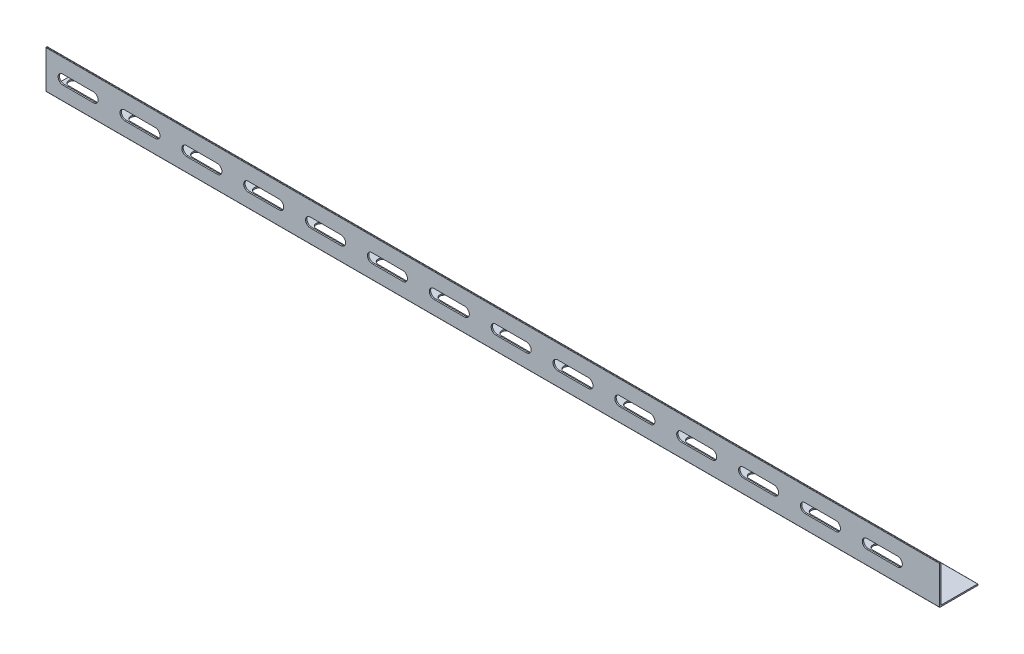
from build123d import *

# Parameters (mm, degrees)
EXTRUDE_1_DEPTH     = 650
CUT_EXTRUDE_1_REACH = 30
CUT_EXTRUDE_2_REACH = 3


with BuildPart() as part:
    # 草图1 → 凸台-拉伸1 (new body)
    with BuildSketch(Plane(origin=(0, 0, 0), x_dir=(0, 0, -1), z_dir=(1, 0, 0))):
        with BuildLine():
            Line((0, 0), (-5.481376518, 0))
            ThreePointArc((-5.481376518, 0), (-5.693508553, 0.087867966), (-5.781376518, 0.3))
            Line((-5.781376518, 0.3), (-5.781376518, 27.7))
            ThreePointArc((-5.781376518, 27.7), (-5.693508553, 27.912132034), (-5.481376518, 28))
            Line((-5.481376518, 28), (-5.081376518, 28))
            ThreePointArc((-5.081376518, 28), (-4.869244484, 27.912132034), (-4.781376518, 27.7))
            Line((-4.781376518, 27.7), (-4.781376518, 1.3))
            ThreePointArc((-4.781376518, 1.3), (-4.693508553, 1.087867966), (-4.481376518, 1))
            Line((-4.481376518, 1), (21.918623482, 1))
            ThreePointArc((21.918623482, 1), (22.130755516, 0.912132034), (22.218623482, 0.7))
            Line((22.218623482, 0.7), (22.218623482, 0.3))
            ThreePointArc((22.218623482, 0.3), (22.130755516, 0.087867966), (21.918623482, 0))
            Line((21.918623482, 0), (0, 0))
        make_face()
    extrude(amount=EXTRUDE_1_DEPTH)

    # 草图2 → 切除-拉伸1 (cut, up to next)
    with BuildSketch(Plane.XY.offset(5.781376518), mode=Mode.PRIVATE) as cut_extrude_1_sk1:
        with BuildLine():
            Line((12.252327797, 17.149656468), (34.50863052, 17.149656468))
            ThreePointArc((34.50863052, 17.149656468), (37.943978067, 13.714308921), (34.50863052, 10.278961375))
            Line((34.50863052, 10.278961375), (12.252327797, 10.278961375))
            ThreePointArc((12.252327797, 10.278961375), (8.816980251, 13.714308921), (12.252327797, 17.149656468))
        make_face()
    cut_extrude_1_tool1 = extrude(cut_extrude_1_sk1.sketch, amount=-CUT_EXTRUDE_1_REACH, mode=Mode.PRIVATE) & part.part
    add(cut_extrude_1_tool1.solids().sort_by_distance((23.380479, 13.714309, 5.781377))[0], mode=Mode.SUBTRACT)
    # 草图2 → 切除-拉伸1 (cut, up to next)
    with BuildSketch(Plane.XY.offset(5.781376518), mode=Mode.PRIVATE) as cut_extrude_1_sk2:
        with BuildLine():
            Line((57.252327797, 17.149656468), (79.50863052, 17.149656468))
            ThreePointArc((79.50863052, 17.149656468), (82.943978067, 13.714308921), (79.50863052, 10.278961375))
            Line((79.50863052, 10.278961375), (57.252327797, 10.278961375))
            ThreePointArc((57.252327797, 10.278961375), (53.816980251, 13.714308921), (57.252327797, 17.149656468))
        make_face()
    cut_extrude_1_tool2 = extrude(cut_extrude_1_sk2.sketch, amount=-CUT_EXTRUDE_1_REACH, mode=Mode.PRIVATE) & part.part
    add(cut_extrude_1_tool2.solids().sort_by_distance((68.380479, 13.714309, 5.781377))[0], mode=Mode.SUBTRACT)
    # 草图2 → 切除-拉伸1 (cut, up to next)
    with BuildSketch(Plane.XY.offset(5.781376518), mode=Mode.PRIVATE) as cut_extrude_1_sk3:
        with BuildLine():
            Line((102.252327797, 17.149656468), (124.50863052, 17.149656468))
            ThreePointArc((124.50863052, 17.149656468), (127.943978067, 13.714308921), (124.50863052, 10.278961375))
            Line((124.50863052, 10.278961375), (102.252327797, 10.278961375))
            ThreePointArc((102.252327797, 10.278961375), (98.816980251, 13.714308921), (102.252327797, 17.149656468))
        make_face()
    cut_extrude_1_tool3 = extrude(cut_extrude_1_sk3.sketch, amount=-CUT_EXTRUDE_1_REACH, mode=Mode.PRIVATE) & part.part
    add(cut_extrude_1_tool3.solids().sort_by_distance((113.380479, 13.714309, 5.781377))[0], mode=Mode.SUBTRACT)
    # 草图2 → 切除-拉伸1 (cut, up to next)
    with BuildSketch(Plane.XY.offset(5.781376518), mode=Mode.PRIVATE) as cut_extrude_1_sk4:
        with BuildLine():
            Line((147.252327797, 17.149656468), (169.50863052, 17.149656468))
            ThreePointArc((169.50863052, 17.149656468), (172.943978067, 13.714308921), (169.50863052, 10.278961375))
            Line((169.50863052, 10.278961375), (147.252327797, 10.278961375))
            ThreePointArc((147.252327797, 10.278961375), (143.816980251, 13.714308921), (147.252327797, 17.149656468))
        make_face()
    cut_extrude_1_tool4 = extrude(cut_extrude_1_sk4.sketch, amount=-CUT_EXTRUDE_1_REACH, mode=Mode.PRIVATE) & part.part
    add(cut_extrude_1_tool4.solids().sort_by_distance((158.380479, 13.714309, 5.781377))[0], mode=Mode.SUBTRACT)
    # 草图2 → 切除-拉伸1 (cut, up to next)
    with BuildSketch(Plane.XY.offset(5.781376518), mode=Mode.PRIVATE) as cut_extrude_1_sk5:
        with BuildLine():
            Line((192.252327797, 17.149656468), (214.50863052, 17.149656468))
            ThreePointArc((214.50863052, 17.149656468), (217.943978067, 13.714308921), (214.50863052, 10.278961375))
            Line((214.50863052, 10.278961375), (192.252327797, 10.278961375))
            ThreePointArc((192.252327797, 10.278961375), (188.816980251, 13.714308921), (192.252327797, 17.149656468))
        make_face()
    cut_extrude_1_tool5 = extrude(cut_extrude_1_sk5.sketch, amount=-CUT_EXTRUDE_1_REACH, mode=Mode.PRIVATE) & part.part
    add(cut_extrude_1_tool5.solids().sort_by_distance((203.380479, 13.714309, 5.781377))[0], mode=Mode.SUBTRACT)
    # 草图2 → 切除-拉伸1 (cut, up to next)
    with BuildSketch(Plane.XY.offset(5.781376518), mode=Mode.PRIVATE) as cut_extrude_1_sk6:
        with BuildLine():
            Line((237.252327797, 17.149656468), (259.50863052, 17.149656468))
            ThreePointArc((259.50863052, 17.149656468), (262.943978067, 13.714308921), (259.50863052, 10.278961375))
            Line((259.50863052, 10.278961375), (237.252327797, 10.278961375))
            ThreePointArc((237.252327797, 10.278961375), (233.816980251, 13.714308921), (237.252327797, 17.149656468))
        make_face()
    cut_extrude_1_tool6 = extrude(cut_extrude_1_sk6.sketch, amount=-CUT_EXTRUDE_1_REACH, mode=Mode.PRIVATE) & part.part
    add(cut_extrude_1_tool6.solids().sort_by_distance((248.380479, 13.714309, 5.781377))[0], mode=Mode.SUBTRACT)
    # 草图2 → 切除-拉伸1 (cut, up to next)
    with BuildSketch(Plane.XY.offset(5.781376518), mode=Mode.PRIVATE) as cut_extrude_1_sk7:
        with BuildLine():
            Line((282.252327797, 17.149656468), (304.50863052, 17.149656468))
            ThreePointArc((304.50863052, 17.149656468), (307.943978067, 13.714308921), (304.50863052, 10.278961375))
            Line((304.50863052, 10.278961375), (282.252327797, 10.278961375))
            ThreePointArc((282.252327797, 10.278961375), (278.816980251, 13.714308921), (282.252327797, 17.149656468))
        make_face()
    cut_extrude_1_tool7 = extrude(cut_extrude_1_sk7.sketch, amount=-CUT_EXTRUDE_1_REACH, mode=Mode.PRIVATE) & part.part
    add(cut_extrude_1_tool7.solids().sort_by_distance((293.380479, 13.714309, 5.781377))[0], mode=Mode.SUBTRACT)
    # 草图2 → 切除-拉伸1 (cut, up to next)
    with BuildSketch(Plane.XY.offset(5.781376518), mode=Mode.PRIVATE) as cut_extrude_1_sk8:
        with BuildLine():
            Line((327.252327797, 17.149656468), (349.50863052, 17.149656468))
            ThreePointArc((349.50863052, 17.149656468), (352.943978067, 13.714308921), (349.50863052, 10.278961375))
            Line((349.50863052, 10.278961375), (327.252327797, 10.278961375))
            ThreePointArc((327.252327797, 10.278961375), (323.816980251, 13.714308921), (327.252327797, 17.149656468))
        make_face()
    cut_extrude_1_tool8 = extrude(cut_extrude_1_sk8.sketch, amount=-CUT_EXTRUDE_1_REACH, mode=Mode.PRIVATE) & part.part
    add(cut_extrude_1_tool8.solids().sort_by_distance((338.380479, 13.714309, 5.781377))[0], mode=Mode.SUBTRACT)
    # 草图2 → 切除-拉伸1 (cut, up to next)
    with BuildSketch(Plane.XY.offset(5.781376518), mode=Mode.PRIVATE) as cut_extrude_1_sk9:
        with BuildLine():
            Line((372.252327797, 17.149656468), (394.50863052, 17.149656468))
            ThreePointArc((394.50863052, 17.149656468), (397.943978067, 13.714308921), (394.50863052, 10.278961375))
            Line((394.50863052, 10.278961375), (372.252327797, 10.278961375))
            ThreePointArc((372.252327797, 10.278961375), (368.816980251, 13.714308921), (372.252327797, 17.149656468))
        make_face()
    cut_extrude_1_tool9 = extrude(cut_extrude_1_sk9.sketch, amount=-CUT_EXTRUDE_1_REACH, mode=Mode.PRIVATE) & part.part
    add(cut_extrude_1_tool9.solids().sort_by_distance((383.380479, 13.714309, 5.781377))[0], mode=Mode.SUBTRACT)
    # 草图2 → 切除-拉伸1 (cut, up to next)
    with BuildSketch(Plane.XY.offset(5.781376518), mode=Mode.PRIVATE) as cut_extrude_1_sk10:
        with BuildLine():
            Line((417.252327797, 17.149656468), (439.50863052, 17.149656468))
            ThreePointArc((439.50863052, 17.149656468), (442.943978067, 13.714308921), (439.50863052, 10.278961375))
            Line((439.50863052, 10.278961375), (417.252327797, 10.278961375))
            ThreePointArc((417.252327797, 10.278961375), (413.816980251, 13.714308921), (417.252327797, 17.149656468))
        make_face()
    cut_extrude_1_tool10 = extrude(cut_extrude_1_sk10.sketch, amount=-CUT_EXTRUDE_1_REACH, mode=Mode.PRIVATE) & part.part
    add(cut_extrude_1_tool10.solids().sort_by_distance((428.380479, 13.714309, 5.781377))[0], mode=Mode.SUBTRACT)
    # 草图2 → 切除-拉伸1 (cut, up to next)
    with BuildSketch(Plane.XY.offset(5.781376518), mode=Mode.PRIVATE) as cut_extrude_1_sk11:
        with BuildLine():
            Line((462.252327797, 17.149656468), (484.50863052, 17.149656468))
            ThreePointArc((484.50863052, 17.149656468), (487.943978067, 13.714308921), (484.50863052, 10.278961375))
            Line((484.50863052, 10.278961375), (462.252327797, 10.278961375))
            ThreePointArc((462.252327797, 10.278961375), (458.816980251, 13.714308921), (462.252327797, 17.149656468))
        make_face()
    cut_extrude_1_tool11 = extrude(cut_extrude_1_sk11.sketch, amount=-CUT_EXTRUDE_1_REACH, mode=Mode.PRIVATE) & part.part
    add(cut_extrude_1_tool11.solids().sort_by_distance((473.380479, 13.714309, 5.781377))[0], mode=Mode.SUBTRACT)
    # 草图2 → 切除-拉伸1 (cut, up to next)
    with BuildSketch(Plane.XY.offset(5.781376518), mode=Mode.PRIVATE) as cut_extrude_1_sk12:
        with BuildLine():
            Line((507.252327797, 17.149656468), (529.50863052, 17.149656468))
            ThreePointArc((529.50863052, 17.149656468), (532.943978067, 13.714308921), (529.50863052, 10.278961375))
            Line((529.50863052, 10.278961375), (507.252327797, 10.278961375))
            ThreePointArc((507.252327797, 10.278961375), (503.816980251, 13.714308921), (507.252327797, 17.149656468))
        make_face()
    cut_extrude_1_tool12 = extrude(cut_extrude_1_sk12.sketch, amount=-CUT_EXTRUDE_1_REACH, mode=Mode.PRIVATE) & part.part
    add(cut_extrude_1_tool12.solids().sort_by_distance((518.380479, 13.714309, 5.781377))[0], mode=Mode.SUBTRACT)
    # 草图2 → 切除-拉伸1 (cut, up to next)
    with BuildSketch(Plane.XY.offset(5.781376518), mode=Mode.PRIVATE) as cut_extrude_1_sk13:
        with BuildLine():
            Line((552.252327797, 17.149656468), (574.50863052, 17.149656468))
            ThreePointArc((574.50863052, 17.149656468), (577.943978067, 13.714308921), (574.50863052, 10.278961375))
            Line((574.50863052, 10.278961375), (552.252327797, 10.278961375))
            ThreePointArc((552.252327797, 10.278961375), (548.816980251, 13.714308921), (552.252327797, 17.149656468))
        make_face()
    cut_extrude_1_tool13 = extrude(cut_extrude_1_sk13.sketch, amount=-CUT_EXTRUDE_1_REACH, mode=Mode.PRIVATE) & part.part
    add(cut_extrude_1_tool13.solids().sort_by_distance((563.380479, 13.714309, 5.781377))[0], mode=Mode.SUBTRACT)
    # 草图2 → 切除-拉伸1 (cut, up to next)
    with BuildSketch(Plane.XY.offset(5.781376518), mode=Mode.PRIVATE) as cut_extrude_1_sk14:
        with BuildLine():
            Line((597.252327797, 17.149656468), (619.50863052, 17.149656468))
            ThreePointArc((619.50863052, 17.149656468), (622.943978067, 13.714308921), (619.50863052, 10.278961375))
            Line((619.50863052, 10.278961375), (597.252327797, 10.278961375))
            ThreePointArc((597.252327797, 10.278961375), (593.816980251, 13.714308921), (597.252327797, 17.149656468))
        make_face()
    cut_extrude_1_tool14 = extrude(cut_extrude_1_sk14.sketch, amount=-CUT_EXTRUDE_1_REACH, mode=Mode.PRIVATE) & part.part
    add(cut_extrude_1_tool14.solids().sort_by_distance((608.380479, 13.714309, 5.781377))[0], mode=Mode.SUBTRACT)

    # 草图3 → 切除-拉伸2 (cut, up to next)
    with BuildSketch(Plane(origin=(0, 1, 0), x_dir=(1, 0, 0), z_dir=(0, 1, 0)), mode=Mode.PRIVATE) as cut_extrude_2_sk1:
        with BuildLine():
            Line((5.656501178, 12.068493885), (27.912803901, 12.068493885))
            ThreePointArc((27.912803901, 12.068493885), (31.348151448, 8.633146338), (27.912803901, 5.197798792))
            Line((27.912803901, 5.197798792), (5.656501178, 5.197798792))
            ThreePointArc((5.656501178, 5.197798792), (2.221153632, 8.633146338), (5.656501178, 12.068493885))
        make_face()
    cut_extrude_2_tool1 = extrude(cut_extrude_2_sk1.sketch, amount=-CUT_EXTRUDE_2_REACH, mode=Mode.PRIVATE) & part.part
    add(cut_extrude_2_tool1.solids().sort_by_distance((16.784653, 1, -8.633146))[0], mode=Mode.SUBTRACT)
    # 草图3 → 切除-拉伸2 (cut, up to next)
    with BuildSketch(Plane(origin=(0, 1, 0), x_dir=(1, 0, 0), z_dir=(0, 1, 0)), mode=Mode.PRIVATE) as cut_extrude_2_sk2:
        with BuildLine():
            Line((50.656501178, 12.068493885), (72.912803901, 12.068493885))
            ThreePointArc((72.912803901, 12.068493885), (76.348151448, 8.633146338), (72.912803901, 5.197798792))
            Line((72.912803901, 5.197798792), (50.656501178, 5.197798792))
            ThreePointArc((50.656501178, 5.197798792), (47.221153632, 8.633146338), (50.656501178, 12.068493885))
        make_face()
    cut_extrude_2_tool2 = extrude(cut_extrude_2_sk2.sketch, amount=-CUT_EXTRUDE_2_REACH, mode=Mode.PRIVATE) & part.part
    add(cut_extrude_2_tool2.solids().sort_by_distance((61.784653, 1, -8.633146))[0], mode=Mode.SUBTRACT)
    # 草图3 → 切除-拉伸2 (cut, up to next)
    with BuildSketch(Plane(origin=(0, 1, 0), x_dir=(1, 0, 0), z_dir=(0, 1, 0)), mode=Mode.PRIVATE) as cut_extrude_2_sk3:
        with BuildLine():
            Line((95.656501178, 12.068493885), (117.912803901, 12.068493885))
            ThreePointArc((117.912803901, 12.068493885), (121.348151448, 8.633146338), (117.912803901, 5.197798792))
            Line((117.912803901, 5.197798792), (95.656501178, 5.197798792))
            ThreePointArc((95.656501178, 5.197798792), (92.221153632, 8.633146338), (95.656501178, 12.068493885))
        make_face()
    cut_extrude_2_tool3 = extrude(cut_extrude_2_sk3.sketch, amount=-CUT_EXTRUDE_2_REACH, mode=Mode.PRIVATE) & part.part
    add(cut_extrude_2_tool3.solids().sort_by_distance((106.784653, 1, -8.633146))[0], mode=Mode.SUBTRACT)
    # 草图3 → 切除-拉伸2 (cut, up to next)
    with BuildSketch(Plane(origin=(0, 1, 0), x_dir=(1, 0, 0), z_dir=(0, 1, 0)), mode=Mode.PRIVATE) as cut_extrude_2_sk4:
        with BuildLine():
            Line((140.656501178, 12.068493885), (162.912803901, 12.068493885))
            ThreePointArc((162.912803901, 12.068493885), (166.348151448, 8.633146338), (162.912803901, 5.197798792))
            Line((162.912803901, 5.197798792), (140.656501178, 5.197798792))
            ThreePointArc((140.656501178, 5.197798792), (137.221153632, 8.633146338), (140.656501178, 12.068493885))
        make_face()
    cut_extrude_2_tool4 = extrude(cut_extrude_2_sk4.sketch, amount=-CUT_EXTRUDE_2_REACH, mode=Mode.PRIVATE) & part.part
    add(cut_extrude_2_tool4.solids().sort_by_distance((151.784653, 1, -8.633146))[0], mode=Mode.SUBTRACT)
    # 草图3 → 切除-拉伸2 (cut, up to next)
    with BuildSketch(Plane(origin=(0, 1, 0), x_dir=(1, 0, 0), z_dir=(0, 1, 0)), mode=Mode.PRIVATE) as cut_extrude_2_sk5:
        with BuildLine():
            Line((185.656501178, 12.068493885), (207.912803901, 12.068493885))
            ThreePointArc((207.912803901, 12.068493885), (211.348151448, 8.633146338), (207.912803901, 5.197798792))
            Line((207.912803901, 5.197798792), (185.656501178, 5.197798792))
            ThreePointArc((185.656501178, 5.197798792), (182.221153632, 8.633146338), (185.656501178, 12.068493885))
        make_face()
    cut_extrude_2_tool5 = extrude(cut_extrude_2_sk5.sketch, amount=-CUT_EXTRUDE_2_REACH, mode=Mode.PRIVATE) & part.part
    add(cut_extrude_2_tool5.solids().sort_by_distance((196.784653, 1, -8.633146))[0], mode=Mode.SUBTRACT)
    # 草图3 → 切除-拉伸2 (cut, up to next)
    with BuildSketch(Plane(origin=(0, 1, 0), x_dir=(1, 0, 0), z_dir=(0, 1, 0)), mode=Mode.PRIVATE) as cut_extrude_2_sk6:
        with BuildLine():
            Line((230.656501178, 12.068493885), (252.912803901, 12.068493885))
            ThreePointArc((252.912803901, 12.068493885), (256.348151448, 8.633146338), (252.912803901, 5.197798792))
            Line((252.912803901, 5.197798792), (230.656501178, 5.197798792))
            ThreePointArc((230.656501178, 5.197798792), (227.221153632, 8.633146338), (230.656501178, 12.068493885))
        make_face()
    cut_extrude_2_tool6 = extrude(cut_extrude_2_sk6.sketch, amount=-CUT_EXTRUDE_2_REACH, mode=Mode.PRIVATE) & part.part
    add(cut_extrude_2_tool6.solids().sort_by_distance((241.784653, 1, -8.633146))[0], mode=Mode.SUBTRACT)
    # 草图3 → 切除-拉伸2 (cut, up to next)
    with BuildSketch(Plane(origin=(0, 1, 0), x_dir=(1, 0, 0), z_dir=(0, 1, 0)), mode=Mode.PRIVATE) as cut_extrude_2_sk7:
        with BuildLine():
            Line((275.656501178, 12.068493885), (297.912803901, 12.068493885))
            ThreePointArc((297.912803901, 12.068493885), (301.348151448, 8.633146338), (297.912803901, 5.197798792))
            Line((297.912803901, 5.197798792), (275.656501178, 5.197798792))
            ThreePointArc((275.656501178, 5.197798792), (272.221153632, 8.633146338), (275.656501178, 12.068493885))
        make_face()
    cut_extrude_2_tool7 = extrude(cut_extrude_2_sk7.sketch, amount=-CUT_EXTRUDE_2_REACH, mode=Mode.PRIVATE) & part.part
    add(cut_extrude_2_tool7.solids().sort_by_distance((286.784653, 1, -8.633146))[0], mode=Mode.SUBTRACT)
    # 草图3 → 切除-拉伸2 (cut, up to next)
    with BuildSketch(Plane(origin=(0, 1, 0), x_dir=(1, 0, 0), z_dir=(0, 1, 0)), mode=Mode.PRIVATE) as cut_extrude_2_sk8:
        with BuildLine():
            Line((320.656501178, 12.068493885), (342.912803901, 12.068493885))
            ThreePointArc((342.912803901, 12.068493885), (346.348151448, 8.633146338), (342.912803901, 5.197798792))
            Line((342.912803901, 5.197798792), (320.656501178, 5.197798792))
            ThreePointArc((320.656501178, 5.197798792), (317.221153632, 8.633146338), (320.656501178, 12.068493885))
        make_face()
    cut_extrude_2_tool8 = extrude(cut_extrude_2_sk8.sketch, amount=-CUT_EXTRUDE_2_REACH, mode=Mode.PRIVATE) & part.part
    add(cut_extrude_2_tool8.solids().sort_by_distance((331.784653, 1, -8.633146))[0], mode=Mode.SUBTRACT)
    # 草图3 → 切除-拉伸2 (cut, up to next)
    with BuildSketch(Plane(origin=(0, 1, 0), x_dir=(1, 0, 0), z_dir=(0, 1, 0)), mode=Mode.PRIVATE) as cut_extrude_2_sk9:
        with BuildLine():
            Line((365.656501178, 12.068493885), (387.912803901, 12.068493885))
            ThreePointArc((387.912803901, 12.068493885), (391.348151448, 8.633146338), (387.912803901, 5.197798792))
            Line((387.912803901, 5.197798792), (365.656501178, 5.197798792))
            ThreePointArc((365.656501178, 5.197798792), (362.221153632, 8.633146338), (365.656501178, 12.068493885))
        make_face()
    cut_extrude_2_tool9 = extrude(cut_extrude_2_sk9.sketch, amount=-CUT_EXTRUDE_2_REACH, mode=Mode.PRIVATE) & part.part
    add(cut_extrude_2_tool9.solids().sort_by_distance((376.784653, 1, -8.633146))[0], mode=Mode.SUBTRACT)
    # 草图3 → 切除-拉伸2 (cut, up to next)
    with BuildSketch(Plane(origin=(0, 1, 0), x_dir=(1, 0, 0), z_dir=(0, 1, 0)), mode=Mode.PRIVATE) as cut_extrude_2_sk10:
        with BuildLine():
            Line((410.656501178, 12.068493885), (432.912803901, 12.068493885))
            ThreePointArc((432.912803901, 12.068493885), (436.348151448, 8.633146338), (432.912803901, 5.197798792))
            Line((432.912803901, 5.197798792), (410.656501178, 5.197798792))
            ThreePointArc((410.656501178, 5.197798792), (407.221153632, 8.633146338), (410.656501178, 12.068493885))
        make_face()
    cut_extrude_2_tool10 = extrude(cut_extrude_2_sk10.sketch, amount=-CUT_EXTRUDE_2_REACH, mode=Mode.PRIVATE) & part.part
    add(cut_extrude_2_tool10.solids().sort_by_distance((421.784653, 1, -8.633146))[0], mode=Mode.SUBTRACT)
    # 草图3 → 切除-拉伸2 (cut, up to next)
    with BuildSketch(Plane(origin=(0, 1, 0), x_dir=(1, 0, 0), z_dir=(0, 1, 0)), mode=Mode.PRIVATE) as cut_extrude_2_sk11:
        with BuildLine():
            Line((455.656501178, 12.068493885), (477.912803901, 12.068493885))
            ThreePointArc((477.912803901, 12.068493885), (481.348151448, 8.633146338), (477.912803901, 5.197798792))
            Line((477.912803901, 5.197798792), (455.656501178, 5.197798792))
            ThreePointArc((455.656501178, 5.197798792), (452.221153632, 8.633146338), (455.656501178, 12.068493885))
        make_face()
    cut_extrude_2_tool11 = extrude(cut_extrude_2_sk11.sketch, amount=-CUT_EXTRUDE_2_REACH, mode=Mode.PRIVATE) & part.part
    add(cut_extrude_2_tool11.solids().sort_by_distance((466.784653, 1, -8.633146))[0], mode=Mode.SUBTRACT)
    # 草图3 → 切除-拉伸2 (cut, up to next)
    with BuildSketch(Plane(origin=(0, 1, 0), x_dir=(1, 0, 0), z_dir=(0, 1, 0)), mode=Mode.PRIVATE) as cut_extrude_2_sk12:
        with BuildLine():
            Line((500.656501178, 12.068493885), (522.912803901, 12.068493885))
            ThreePointArc((522.912803901, 12.068493885), (526.348151448, 8.633146338), (522.912803901, 5.197798792))
            Line((522.912803901, 5.197798792), (500.656501178, 5.197798792))
            ThreePointArc((500.656501178, 5.197798792), (497.221153632, 8.633146338), (500.656501178, 12.068493885))
        make_face()
    cut_extrude_2_tool12 = extrude(cut_extrude_2_sk12.sketch, amount=-CUT_EXTRUDE_2_REACH, mode=Mode.PRIVATE) & part.part
    add(cut_extrude_2_tool12.solids().sort_by_distance((511.784653, 1, -8.633146))[0], mode=Mode.SUBTRACT)
    # 草图3 → 切除-拉伸2 (cut, up to next)
    with BuildSketch(Plane(origin=(0, 1, 0), x_dir=(1, 0, 0), z_dir=(0, 1, 0)), mode=Mode.PRIVATE) as cut_extrude_2_sk13:
        with BuildLine():
            Line((545.656501178, 12.068493885), (567.912803901, 12.068493885))
            ThreePointArc((567.912803901, 12.068493885), (571.348151448, 8.633146338), (567.912803901, 5.197798792))
            Line((567.912803901, 5.197798792), (545.656501178, 5.197798792))
            ThreePointArc((545.656501178, 5.197798792), (542.221153632, 8.633146338), (545.656501178, 12.068493885))
        make_face()
    cut_extrude_2_tool13 = extrude(cut_extrude_2_sk13.sketch, amount=-CUT_EXTRUDE_2_REACH, mode=Mode.PRIVATE) & part.part
    add(cut_extrude_2_tool13.solids().sort_by_distance((556.784653, 1, -8.633146))[0], mode=Mode.SUBTRACT)
    # 草图3 → 切除-拉伸2 (cut, up to next)
    with BuildSketch(Plane(origin=(0, 1, 0), x_dir=(1, 0, 0), z_dir=(0, 1, 0)), mode=Mode.PRIVATE) as cut_extrude_2_sk14:
        with BuildLine():
            Line((590.656501178, 12.068493885), (612.912803901, 12.068493885))
            ThreePointArc((612.912803901, 12.068493885), (616.348151448, 8.633146338), (612.912803901, 5.197798792))
            Line((612.912803901, 5.197798792), (590.656501178, 5.197798792))
            ThreePointArc((590.656501178, 5.197798792), (587.221153632, 8.633146338), (590.656501178, 12.068493885))
        make_face()
    cut_extrude_2_tool14 = extrude(cut_extrude_2_sk14.sketch, amount=-CUT_EXTRUDE_2_REACH, mode=Mode.PRIVATE) & part.part
    add(cut_extrude_2_tool14.solids().sort_by_distance((601.784653, 1, -8.633146))[0], mode=Mode.SUBTRACT)


solid = part.part
